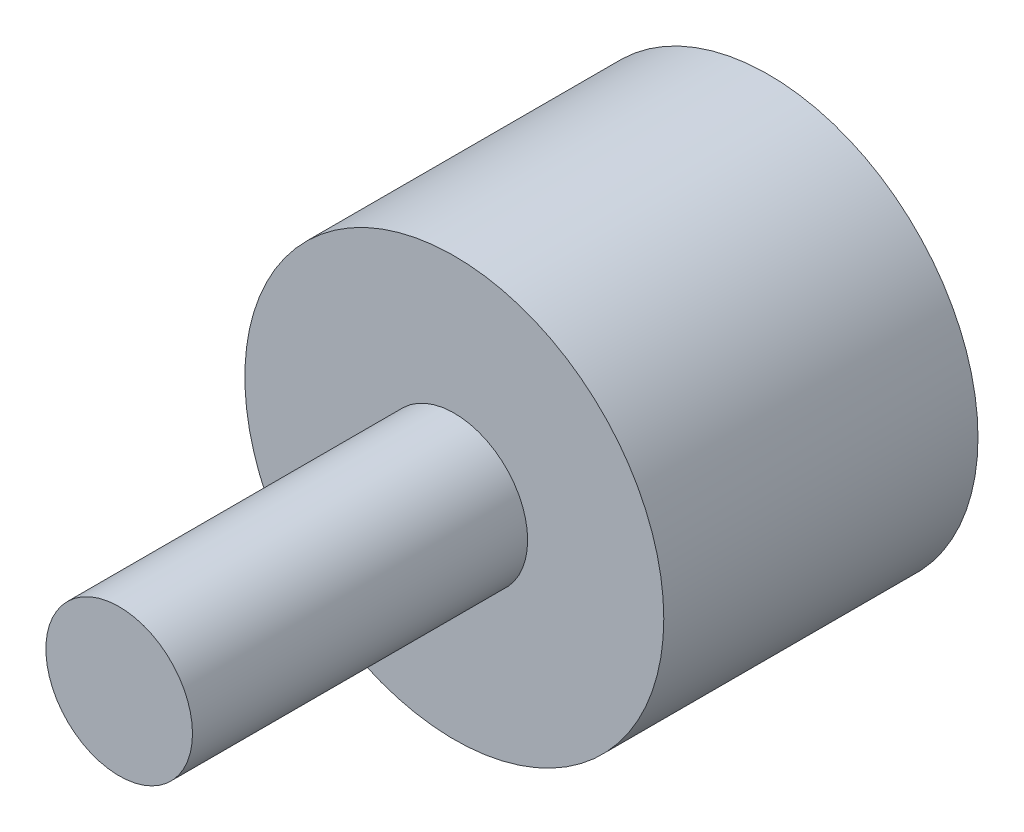
from build123d import *

# Parameters (mm, degrees)
ESQUISSE1_R        = 10
BOSS_EXTRU_1_DEPTH = 15
ESQUISSE2_R        = 3.5
BOSS_EXTRU_2_DEPTH = 16


with BuildPart() as part:
    # Esquisse1 → Boss.-Extru.1 (new body)
    with BuildSketch(Plane.XY):
        Circle(ESQUISSE1_R)
    extrude(amount=BOSS_EXTRU_1_DEPTH)

    # Esquisse2 → Boss.-Extru.2 (add)
    with BuildSketch(Plane.XY.offset(15)):
        Circle(ESQUISSE2_R)
    extrude(amount=BOSS_EXTRU_2_DEPTH)

    # Esquisse3 → Révolution1 (revolve)
    with BuildSketch(Plane(origin=(0, 0, 0), x_dir=(1, 0, 0), z_dir=(0, 1, 0))):
        with BuildLine():
            Line((0, 3), (0, -9))
            ThreePointArc((0, -9), (6, -3), (0, 3))
        make_face()
    revolve(axis=Axis((0, 0, 34.789870501), (0, 0, -1)))


solid = part.part
